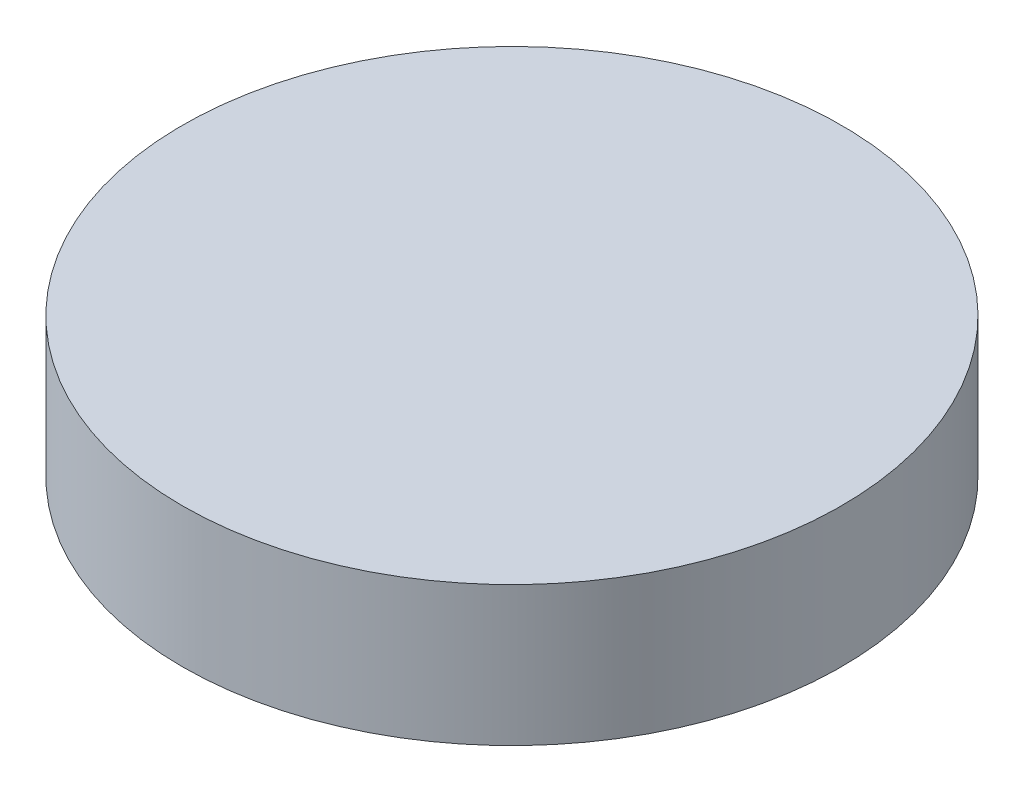
from build123d import *

# Parameters (mm, degrees)
SKETCH1_R           = 39
SKETCH1_R_2         = 36
BOSS_EXTRUDE2_DEPTH = 8.5
SKETCH2_R           = 39
SKETCH2_R_2         = 30
SKETCH2_R_3         = 1.698645883
BOSS_EXTRUDE3_DEPTH = 3.2
SKETCH4_R           = 39
SKETCH4_R_2         = 30
BOSS_EXTRUDE6_DEPTH = 2.8
SKETCH11_R          = 39
BOSS_EXTRUDE7_DEPTH = 2


with BuildPart() as part:
    # Sketch1 → Boss-Extrude2 (new body)
    with BuildSketch(Plane(origin=(0, 0, 0), x_dir=(1, 0, 0), z_dir=(0, 1, 0))):
        Circle(SKETCH1_R)
        Circle(SKETCH1_R_2, mode=Mode.SUBTRACT)
    extrude(amount=BOSS_EXTRUDE2_DEPTH)

    # Sketch2 → Boss-Extrude3 (add)
    with BuildSketch(Plane(origin=(0, 8.5, 0), x_dir=(1, 0, 0), z_dir=(0, 1, 0))):
        Circle(SKETCH2_R)
        Circle(SKETCH2_R_2, mode=Mode.SUBTRACT)
        with Locations((0, 33)):
            Circle(SKETCH2_R_3, mode=Mode.SUBTRACT)
        with Locations((31.384865038, 10.197560814)):
            Circle(SKETCH2_R_3, mode=Mode.SUBTRACT)
        with Locations((19.396913326, -26.697560814)):
            Circle(SKETCH2_R_3, mode=Mode.SUBTRACT)
        with Locations((-19.396913326, -26.697560814)):
            Circle(SKETCH2_R_3, mode=Mode.SUBTRACT)
        with Locations((-31.384865038, 10.197560814)):
            Circle(SKETCH2_R_3, mode=Mode.SUBTRACT)
    extrude(amount=BOSS_EXTRUDE3_DEPTH)

    # Sketch4 → Boss-Extrude6 (add)
    with BuildSketch(Plane(origin=(0, 11.7, 0), x_dir=(1, 0, 0), z_dir=(0, 1, 0))):
        Circle(SKETCH4_R)
        Circle(SKETCH4_R_2, mode=Mode.SUBTRACT)
    extrude(amount=BOSS_EXTRUDE6_DEPTH)

    # Sketch11 → Boss-Extrude7 (add)
    with BuildSketch(Plane(origin=(0, 14.5, 0), x_dir=(1, 0, 0), z_dir=(0, 1, 0))):
        Circle(SKETCH11_R)
    extrude(amount=BOSS_EXTRUDE7_DEPTH)


solid = part.part
